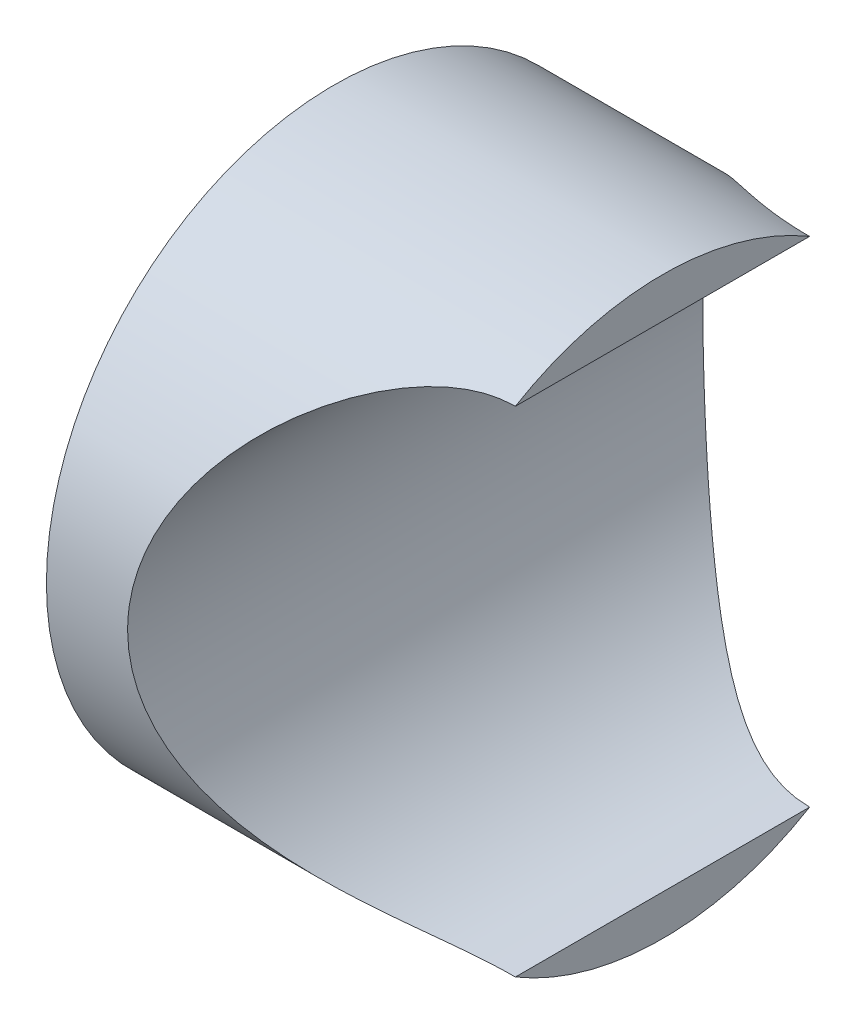
from build123d import *

# Parameters (mm, degrees)
SKETCH5_R           = 5
BOSS_EXTRUDE2_DEPTH = 2


with BuildPart() as part:
    # Sketch1 → Revolve1 (revolve)
    with BuildSketch(Plane(origin=(0, 0, 0), x_dir=(1, 0, 0), z_dir=(0, 1, 0))):
        with BuildLine():
            Line((12.781543507, 13.383116119), (-2.50303312, 13.383116119))
            ThreePointArc((-2.50303312, 13.383116119), (-2.501361875, 13.293526957), (-2.506133274, 13.204049335))
            Line((-2.506133274, 13.204049335), (-2.506133274, 9.63773694))
            Line((-2.506133274, 9.63773694), (0, 9.63773694))
            Line((0, 9.63773694), (0, 3.705))
            Line((0, 3.705), (0, 0))
            Line((0, 0), (4.789576981, 0))
            Line((4.789576981, 0), (4.808638309, 3.705))
            ThreePointArc((4.808638309, 3.705), (5.009621244, 3.664180843), (5.185678757, 3.558994837))
            ThreePointArc((5.185678757, 3.558994837), (7.965698705, 8.014106646), (12.465543511, 10.721121396))
            ThreePointArc((12.465543511, 10.721121396), (12.633558311, 10.915283437), (12.780786925, 11.125644095))
            Line((12.780786925, 11.125644095), (12.781543507, 13.383116119))
        make_face()
    revolve(axis=Axis((0, 0, 0), (1, 0, 0)))

    # Sketch2 → Revolved-Cut2 (revolve, cut)
    with BuildSketch(Plane.ZY.offset(-12.773866726)):
        Polygon((13.385193973, 0), (-13.385193973, 0), (-16.077753665, 0), (-16.077753665, 11.5), (15.518432284, 11.5), (15.518432284, 0), align=None)
    revolve(axis=Axis((12.773866726, 0, -16.077753665), (0, 0, 1)), mode=Mode.SUBTRACT)

    # Sketch5 → Boss-Extrude2 (add)
    with BuildSketch(Plane.ZY):
        Circle(SKETCH5_R)
    extrude(amount=BOSS_EXTRUDE2_DEPTH)


solid = part.part
